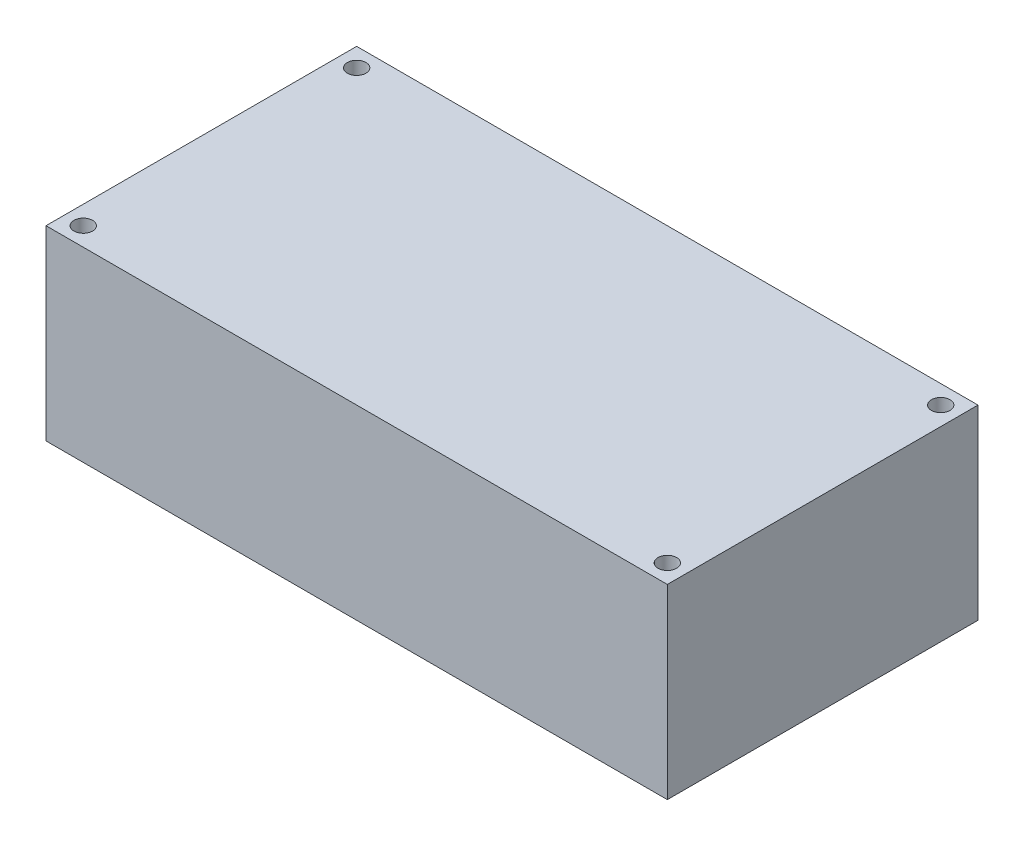
from build123d import *

# Parameters (mm, degrees)
ESQUISSE2_W             = 100
ESQUISSE2_H             = 50
BOSS_EXTRU_1_DEPTH      = 30
ESQUISSE3_R             = 1.5
ENL_V_MAT_EXTRU_1_DEPTH = 30


with BuildPart() as part:
    # Esquisse2 → Boss.-Extru.1 (new body)
    with BuildSketch(Plane(origin=(0, 0, 0), x_dir=(1, 0, 0), z_dir=(0, 1, 0))):
        Rectangle(ESQUISSE2_W, ESQUISSE2_H)
    extrude(amount=BOSS_EXTRU_1_DEPTH)

    # Esquisse3 → Enlèv. mat.-Extru.1 (cut)
    with BuildSketch(Plane(origin=(0, 30, 0), x_dir=(1, 0, 0), z_dir=(0, 1, 0))):
        with Locations((-47, 22)):
            Circle(ESQUISSE3_R)
        with Locations((-47, -22)):
            Circle(ESQUISSE3_R)
        with Locations((47, -22)):
            Circle(ESQUISSE3_R)
        with Locations((47, 22)):
            Circle(ESQUISSE3_R)
    extrude(amount=-ENL_V_MAT_EXTRU_1_DEPTH, mode=Mode.SUBTRACT)


solid = part.part
